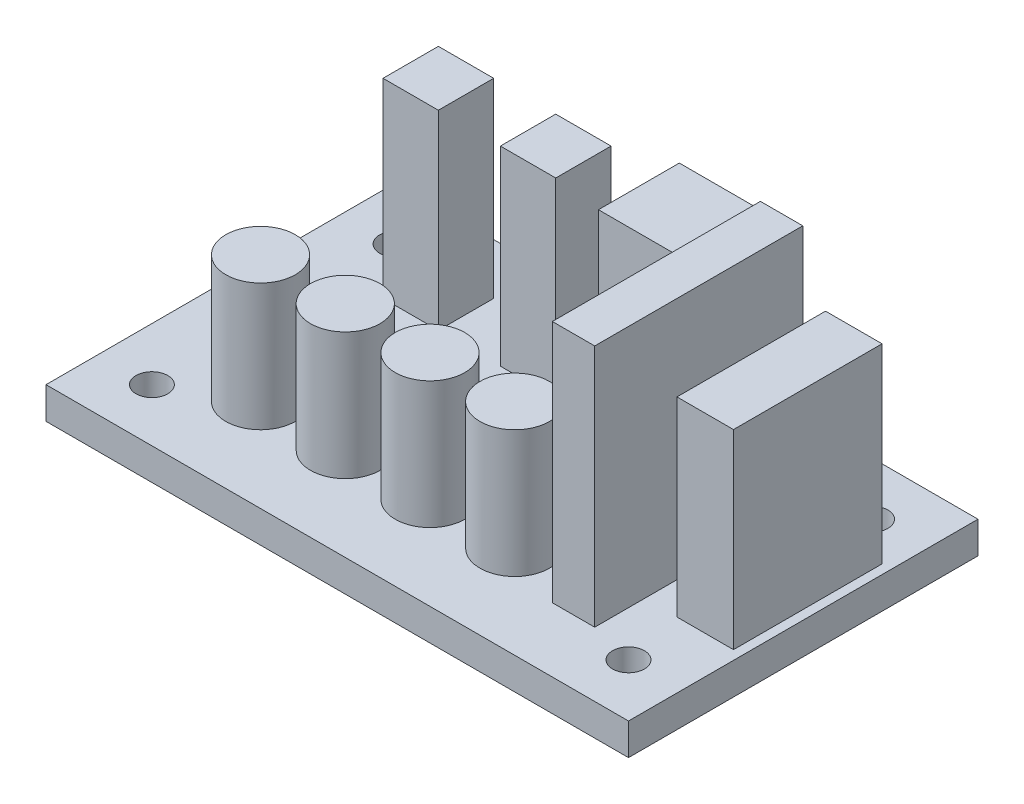
from build123d import *

# Parameters (mm, degrees)
ESQUISSE1_W      = 55
ESQUISSE1_H      = 33
ESQUISSE1_R      = 1.5
EXTRUSION1_DEPTH = 3
ESQUISSE2_W      = 7.634201779
ESQUISSE2_H      = 7.63420178
ESQUISSE2_W_2    = 5.337752956
ESQUISSE2_H_2    = 14.027301674
ESQUISSE2_W_3    = 5.224355128
ESQUISSE2_H_3    = 5.224355128
EXTRUSION2_DEPTH = 18
ESQUISSE3_R      = 3.279080348
EXTRUSION3_DEPTH = 12
ESQUISSE4_W      = 4
ESQUISSE4_H      = 19.646099489
EXTRUSION4_DEPTH = 23


with BuildPart() as part:
    # Esquisse1 → Extrusion1 (new body)
    with BuildSketch(Plane(origin=(0, 0, 0), x_dir=(1, 0, 0), z_dir=(0, 1, 0))):
        with Locations((27.5, 16.5)):
            Rectangle(ESQUISSE1_W, ESQUISSE1_H)
        with Locations((5, 28)):
            Circle(ESQUISSE1_R, mode=Mode.SUBTRACT)
        with Locations((50, 28)):
            Circle(ESQUISSE1_R, mode=Mode.SUBTRACT)
        with Locations((50, 5)):
            Circle(ESQUISSE1_R, mode=Mode.SUBTRACT)
        with Locations((5, 5)):
            Circle(ESQUISSE1_R, mode=Mode.SUBTRACT)
    extrude(amount=EXTRUSION1_DEPTH)

    # Esquisse2 → Extrusion2 (add)
    with BuildSketch(Plane(origin=(0, 3, 0), x_dir=(1, 0, 0), z_dir=(0, 1, 0))):
        with Locations((33.593446124, 26.205676479)):
            Rectangle(ESQUISSE2_W, ESQUISSE2_H)
        with Locations((51.457386868, 17.801055276)):
            Rectangle(ESQUISSE2_W_2, ESQUISSE2_H_2)
        with Locations((11.46939236, 25.577155504)):
            Rectangle(ESQUISSE2_W_3, ESQUISSE2_H_3)
        with Locations((22.552159567, 25.577155504)):
            Rectangle(ESQUISSE2_W_3, ESQUISSE2_H_3)
    extrude(amount=EXTRUSION2_DEPTH)

    # Esquisse3 → Extrusion3 (add)
    with BuildSketch(Plane(origin=(0, 3, 0), x_dir=(1, 0, 0), z_dir=(0, 1, 0))):
        with Locations((11.5, 8.756763264)):
            Circle(ESQUISSE3_R)
        with Locations((19.5, 8.756763264)):
            Circle(ESQUISSE3_R)
        with Locations((27.5, 8.756763264)):
            Circle(ESQUISSE3_R)
        with Locations((35.5, 8.756763264)):
            Circle(ESQUISSE3_R)
    extrude(amount=EXTRUSION3_DEPTH)

    # Esquisse4 → Extrusion4 (add)
    with BuildSketch(Plane(origin=(0, 3, 0), x_dir=(1, 0, 0), z_dir=(0, 1, 0))):
        with Locations((43.737455539, 15.895279312)):
            Rectangle(ESQUISSE4_W, ESQUISSE4_H)
    extrude(amount=EXTRUSION4_DEPTH)


solid = part.part
